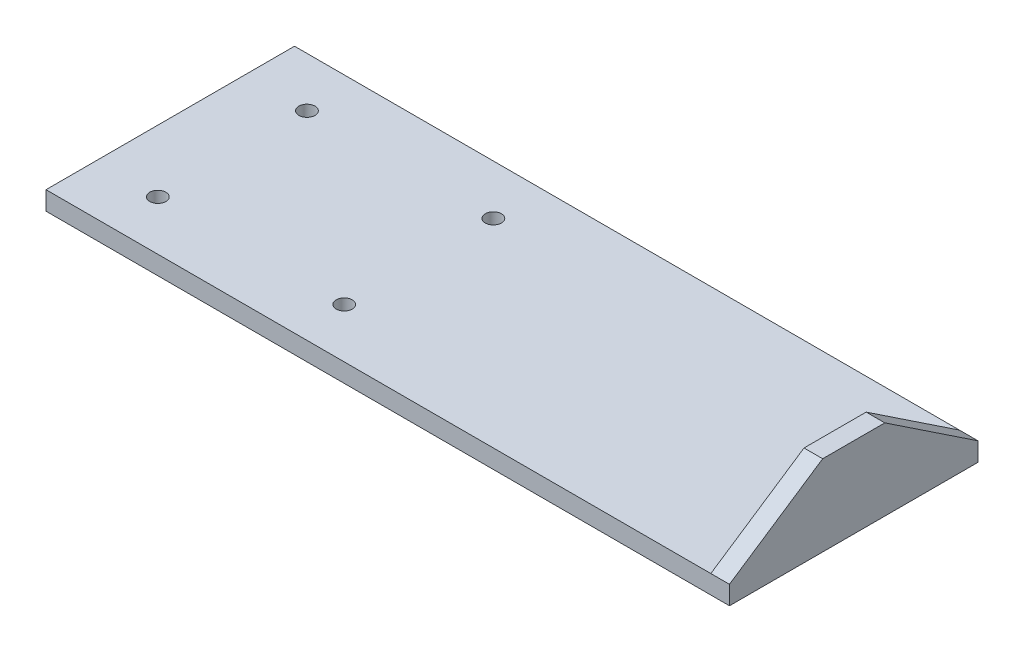
from build123d import *

# Parameters (mm, degrees)
SKETCH1_W               = 550
SKETCH1_H               = 200
EXTRUDE1_DEPTH          = 15
SKETCH3_W               = 15
SKETCH3_H               = 200
EXTRUDE2_DEPTH          = 50
CUT_EXTRUDE3_DEPTH      = 536
CUT_EXTRUDE3_DEPTH_BACK = 16
CUT_EXTRUDE4_DEPTH      = 536
CUT_EXTRUDE4_DEPTH_BACK = 16
SKETCH8_R               = 6.5
CUT_EXTRUDE5_DEPTH      = 16


with BuildPart() as part:
    # Sketch1 → Extrude1 (new body)
    with BuildSketch(Plane(origin=(0, 0, 0), x_dir=(1, 0, 0), z_dir=(0, 1, 0))):
        with Locations((275, 0)):
            Rectangle(SKETCH1_W, SKETCH1_H)
    extrude(amount=-EXTRUDE1_DEPTH)

    # Sketch3 → Extrude2 (add)
    with BuildSketch(Plane(origin=(0, 0, 0), x_dir=(-1, 0, 0), z_dir=(0, 1, 0))):
        with Locations((-542.5, 0)):
            Rectangle(SKETCH3_W, SKETCH3_H)
    extrude(amount=EXTRUDE2_DEPTH)

    # Sketch4 → Cut-Extrude3 (cut, two sides)
    with BuildSketch(Plane.ZY.offset(-535)) as cut_extrude3_sk:
        Polygon((-100, 50), (-100, 0), (-25, 50), align=None)
    extrude(amount=CUT_EXTRUDE3_DEPTH, mode=Mode.SUBTRACT)
    extrude(cut_extrude3_sk.sketch, amount=-CUT_EXTRUDE3_DEPTH_BACK, mode=Mode.SUBTRACT)

    # Sketch7 → Cut-Extrude4 (cut, two sides)
    with BuildSketch(Plane.ZY.offset(-535)) as cut_extrude4_sk:
        Polygon((451.383627881, -234.255751921), (100, 0), (25, 50), (-326.383627881, 284.255751921), (142.12787596, 987.023007684), (919.895131723, 468.511503842), align=None)
    extrude(amount=CUT_EXTRUDE4_DEPTH, mode=Mode.SUBTRACT)
    extrude(cut_extrude4_sk.sketch, amount=-CUT_EXTRUDE4_DEPTH_BACK, mode=Mode.SUBTRACT)

    # Sketch8 → Cut-Extrude5 (cut, through all)
    with BuildSketch(Plane(origin=(0, 0, 0), x_dir=(-1, 0, 0), z_dir=(0, 1, 0))):
        with Locations((-50, -60)):
            Circle(SKETCH8_R)
        with Locations((-200, -60)):
            Circle(SKETCH8_R)
        with Locations((-50, 60)):
            Circle(SKETCH8_R)
        with Locations((-200, 60)):
            Circle(SKETCH8_R)
    extrude(amount=-CUT_EXTRUDE5_DEPTH, mode=Mode.SUBTRACT)


solid = part.part
